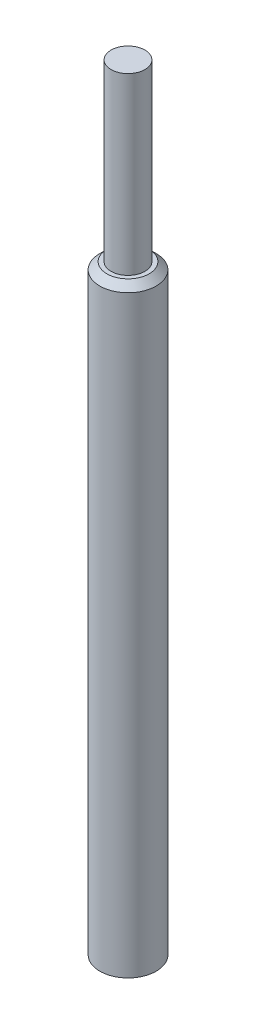
from build123d import *

# Parameters (mm, degrees)
CHAMFER1_SIZE = 2.5


with BuildPart() as part:
    # Sketch1 → Revolve1 (revolve)
    with BuildSketch(Plane.XY):
        Polygon((0, -79.597010697), (10, -79.597010697), (10, 133.402989303), (6, 133.402989303), (6, 195.402989303), (0, 195.402989303), align=None)
    revolve(axis=Axis((0, 61.679068895, 0), (0, 1, 0)))

    # Chamfer1
    chamfer1_edges = [part.edges().sort_by_distance(p)[0] for p in [
        (-10, 133.402989303, 0),
    ]]
    chamfer(chamfer1_edges, length=CHAMFER1_SIZE)


solid = part.part
